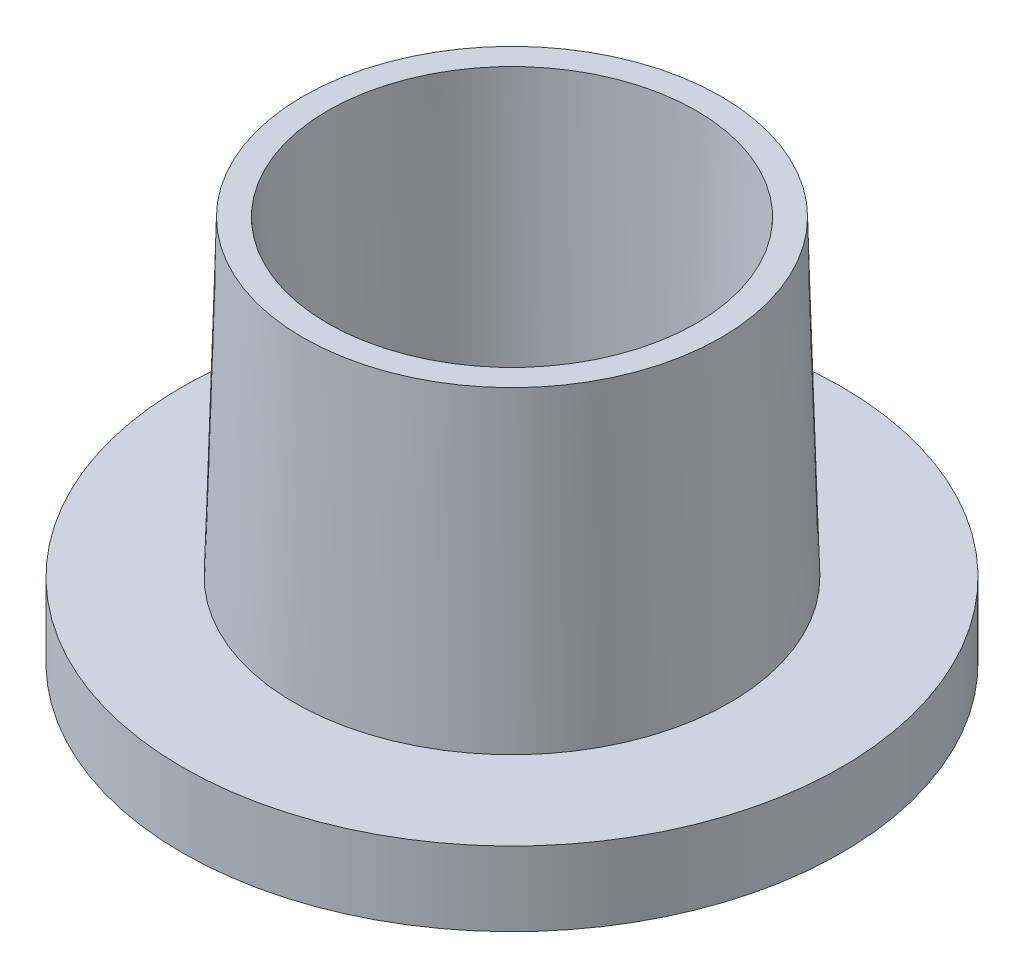
from build123d import *


with BuildPart() as part:
    # Sketch1 → Revolve1 (revolve)
    with BuildSketch(Plane.XY):
        Polygon((-10.6, 0), (-11.185, 23.42), (-12.685, 23.42), (-13.212715846, 4.5), (-20, 4.5), (-20, 0), (-12.1, 0), align=None)
    revolve(axis=Axis((0, 0, 0), (0, 1, 0)))


solid = part.part
